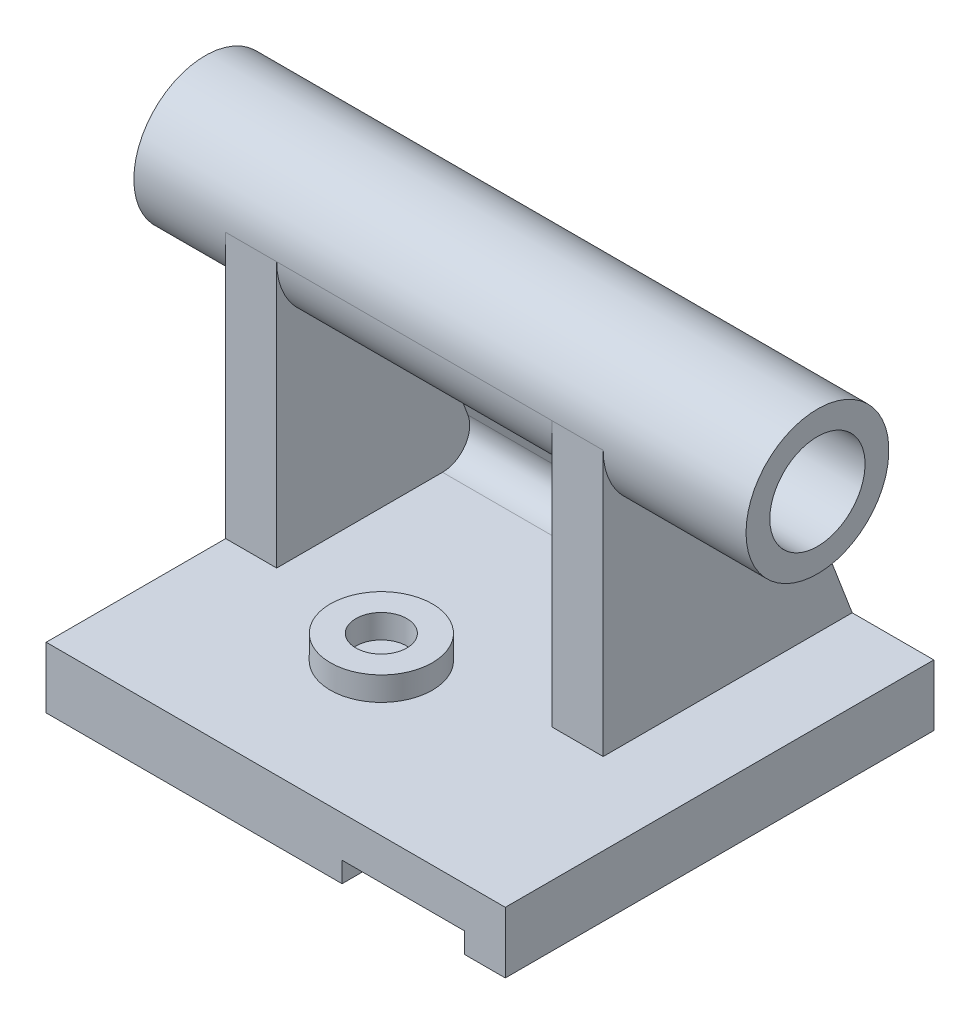
from build123d import *

# Parameters (mm, degrees)
BOSS_EXTRUDE1_DEPTH      = 126
SKETCH2_R                = 21
SKETCH2_R_2              = 14
BOSS_EXTRUDE4_DEPTH      = 27
BOSS_EXTRUDE4_DEPTH_BACK = 153
BOSS_EXTRUDE5_DEPTH      = 15
BOSS_EXTRUDE7_DEPTH      = 15
BOSS_EXTRUDE8_DEPTH      = 111
SKETCH11_R               = 15
SKETCH11_R_2             = 7.5
BOSS_EXTRUDE9_DEPTH      = 7


with BuildPart() as part:
    # Sketch1 → Boss-Extrude1 (new body)
    with BuildSketch(Plane.XY):
        Polygon((19.5, -9), (19.5, -3), (55.5, -3), (55.5, -9), (67.5, -9), (67.5, 9), (-67.5, 9), (-67.5, -9), align=None)
    extrude(amount=BOSS_EXTRUDE1_DEPTH)



with BuildPart() as body_2:
    # Sketch2 → Boss-Extrude4 (new body, two sides)
    with BuildSketch(Plane.ZY.offset(67.5)) as boss_extrude4_sk:
        with Locations((52.218982883, 87)):
            Circle(SKETCH2_R)
        with Locations((52.218982883, 87)):
            Circle(SKETCH2_R_2, mode=Mode.SUBTRACT)
    extrude(amount=BOSS_EXTRUDE4_DEPTH)
    extrude(boss_extrude4_sk.sketch, amount=-BOSS_EXTRUDE4_DEPTH_BACK)


with BuildPart() as part_1:
    add(part.part)

    add(body_2.part)  # Boss-Extrude5 merges body 2
    # Sketch3 → Boss-Extrude5 (add)
    with BuildSketch(Plane.ZY.offset(67.5)):
        with BuildLine():
            Line((73.218982883, 9), (73.218982883, 87))
            ThreePointArc((73.218982883, 87), (67.068225288, 72.150757595), (52.218982883, 66))
            Line((52.218982883, 66), (38.0233764, 66))
            ThreePointArc((38.0233764, 66), (35.18679718, 65.117501467), (33.351528761, 62.781527332))
            Line((33.351528761, 62.781527332), (16.980511395, 19.850443731))
            ThreePointArc((16.980511395, 19.850443731), (17.86746527, 12.461473248), (24.455467618, 9))
            Line((24.455467618, 9), (73.218982883, 9))
        make_face()
    extrude(amount=-BOSS_EXTRUDE5_DEPTH)

    # Sketch7 → Boss-Extrude7 (add)
    with BuildSketch(Plane.ZY.offset(-43.5)):
        with BuildLine():
            Line((73.218982883, 9), (73.218982883, 87))
            ThreePointArc((73.218982883, 87), (67.068225288, 72.150757595), (52.218982883, 66))
            Line((52.218982883, 66), (38.0233764, 66))
            ThreePointArc((38.0233764, 66), (35.18679718, 65.117501467), (33.351528761, 62.781527332))
            Line((33.351528761, 62.781527332), (16.980511395, 19.850443731))
            ThreePointArc((16.980511395, 19.850443731), (17.86746527, 12.461473248), (24.455467618, 9))
            Line((24.455467618, 9), (73.218982883, 9))
        make_face()
    extrude(amount=BOSS_EXTRUDE7_DEPTH)

    # Sketch4 → Boss-Extrude8 (add)
    with BuildSketch(Plane.ZY.offset(67.5)):
        with BuildLine():
            ThreePointArc((52.218982883, 66), (34.925476722, 75.086367277), (32.597222798, 94.482414795))
            Line((32.597222798, 94.482414795), (0, 9))
            Line((0, 9), (24.455467618, 9))
            ThreePointArc((24.455467618, 9), (17.86746527, 12.461473248), (16.980511395, 19.850443731))
            Line((16.980511395, 19.850443731), (33.351528761, 62.781527332))
            ThreePointArc((33.351528761, 62.781527332), (35.18679718, 65.117501467), (38.0233764, 66))
            Line((38.0233764, 66), (52.218982883, 66))
        make_face()
    extrude(amount=-BOSS_EXTRUDE8_DEPTH)

    # Sketch11 → Boss-Extrude9 (add)
    with BuildSketch(Plane(origin=(0, 9, 0), x_dir=(1, 0, 0), z_dir=(0, 1, 0))):
        with Locations((-13.5, -81.444044499)):
            Circle(SKETCH11_R)
        with Locations((-13.5, -81.444044499)):
            Circle(SKETCH11_R_2, mode=Mode.SUBTRACT)
    extrude(amount=BOSS_EXTRUDE9_DEPTH)


solid = part_1.part
